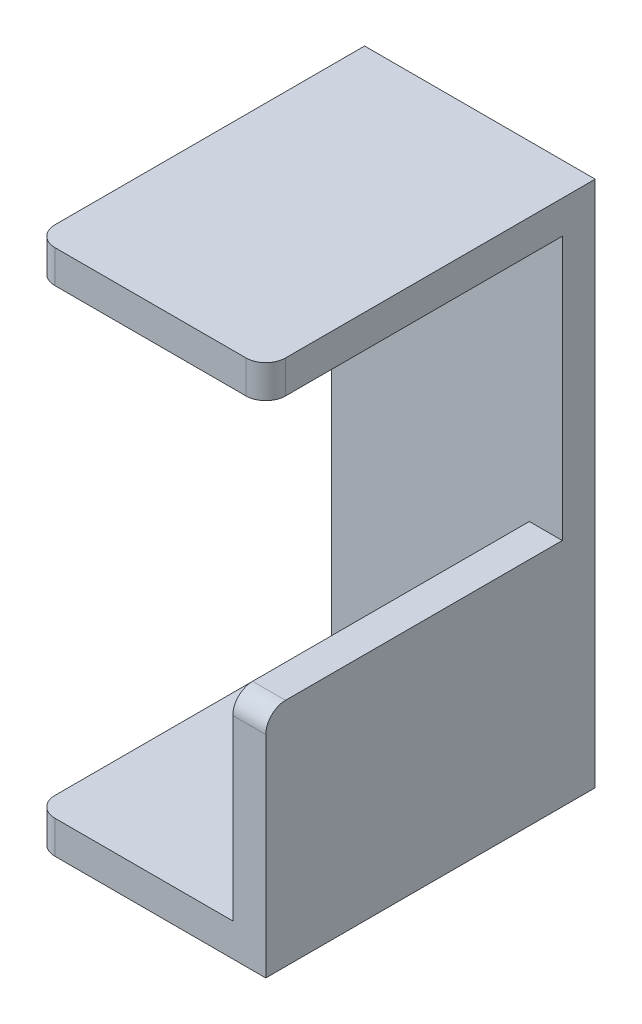
from build123d import *

# Parameters (mm, degrees)
SKETCH_1_W      = 35
SKETCH_1_H      = 80
EXTRUDE_1_DEPTH = 5
SKETCH_2_W      = 35
SKETCH_2_H      = 5
SKETCH_2_W_2    = 30
SKETCH_2_W_3    = 5
SKETCH_2_H_2    = 30
EXTRUDE_2_DEPTH = 45
FILLET_2_R      = 3


with BuildPart() as part:
    # 草圖1 → 填料-伸長1 (new body)
    with BuildSketch(Plane.XY):
        with Locations((-29.638177138, -5.194805195)):
            Rectangle(SKETCH_1_W, SKETCH_1_H)
    extrude(amount=EXTRUDE_1_DEPTH)

    # 草圖2 → 填料-伸長2 (add)
    with BuildSketch(Plane.XY.offset(5)):
        with Locations((-29.638177138, 32.305194805)):
            Rectangle(SKETCH_2_W, SKETCH_2_H)
        with Locations((-32.138177138, -42.694805195)):
            Rectangle(SKETCH_2_W_2, SKETCH_2_H)
        with Locations((-14.638177138, -42.694805195)):
            Rectangle(SKETCH_2_W_3, SKETCH_2_H)
        with Locations((-14.638177138, -25.194805195)):
            Rectangle(SKETCH_2_W_3, SKETCH_2_H_2)
    extrude(amount=EXTRUDE_2_DEPTH)

    # 圓角2
    fillet_2_edges = [part.edges().sort_by_distance(p)[0] for p in [
        (-47.138177138, -42.694805195, 50),
        (-14.638177138, -10.194805195, 50),
        (-47.138177138, 32.305194805, 50),
        (-12.138177138, 32.305194805, 50),
    ]]
    fillet(fillet_2_edges, radius=FILLET_2_R)


solid = part.part
